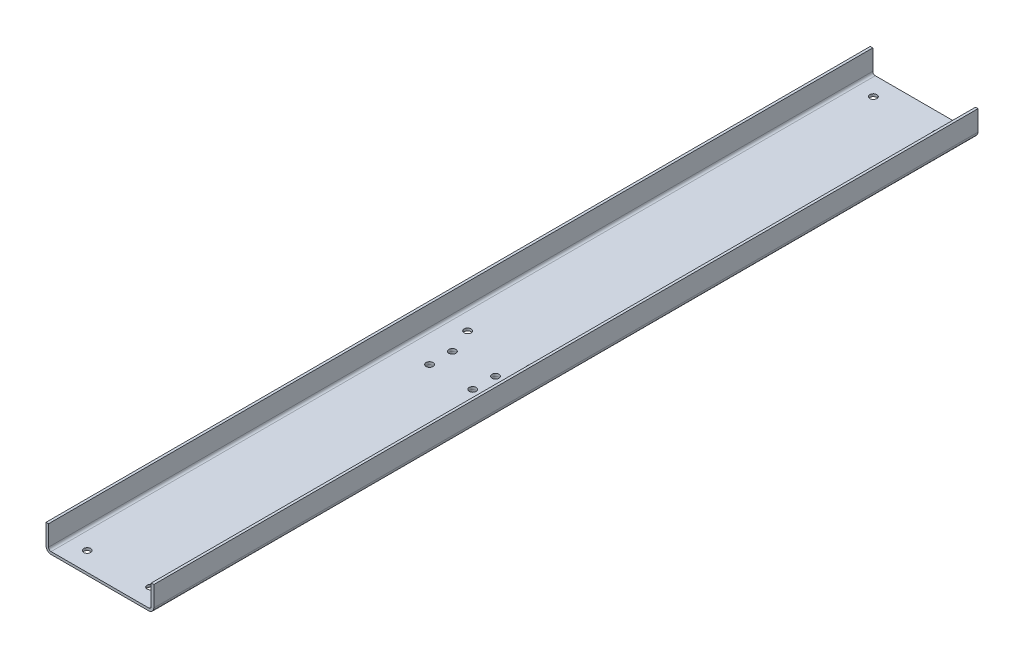
from build123d import *

# Parameters (mm, degrees)
BOSS_EXTRUDE1_DEPTH           = 650
FILLET1_R                     = 2
FILLET2_R                     = 4
SKETCH2_W                     = 46
SKETCH2_H                     = 30
BOSS_EXTRUDE2_DEPTH           = 6
CHAMFER1_SIZE                 = 3
SKETCH3_W                     = 2.75
SKETCH3_H                     = 8
M5_CLEARANCE_HOLE1_AT_2_COUNT = 2
M5_CLEARANCE_HOLE1_AT_2_PITCH = 620
M5_CLEARANCE_HOLE1_AT_3_COUNT = 2
M5_CLEARANCE_HOLE1_AT_3_PITCH = 50
M5_CLEARANCE_HOLE1_AT_4_COUNT = 2
M5_CLEARANCE_HOLE1_AT_4_PITCH = 323.882694814
M5_CLEARANCE_HOLE1_AT_5_COUNT = 2
M5_CLEARANCE_HOLE1_AT_5_PITCH = 320
M5_CLEARANCE_HOLE1_AT_6_COUNT = 2
M5_CLEARANCE_HOLE1_AT_6_PITCH = 622.012861603
SKETCH5_W                     = 2.75
SKETCH5_H                     = 8
M5_CLEARANCE_HOLE2_AT_2_COUNT = 2
M5_CLEARANCE_HOLE2_AT_2_PITCH = 34
M5_CLEARANCE_HOLE2_AT_3_COUNT = 2
M5_CLEARANCE_HOLE2_AT_3_PITCH = 38.470768123
M5_CLEARANCE_HOLE2_AT_4_COUNT = 2
M5_CLEARANCE_HOLE2_AT_4_PITCH = 18


with BuildPart() as part:
    # Sketch1 → Boss-Extrude1 (new body)
    with BuildSketch(Plane.XY):
        Polygon((40.5, 20), (42.5, 20), (42.5, 0), (-42.5, 0), (-42.5, 20), (-40.5, 20), (-40.5, 2), (40.5, 2), align=None)
    extrude(amount=BOSS_EXTRUDE1_DEPTH)

    # Fillet1
    fillet1_edges = [part.edges().sort_by_distance(p)[0] for p in [
        (-40.5, 2, 325),
        (40.5, 2, 325),
    ]]
    fillet(fillet1_edges, radius=FILLET1_R)

    # Fillet2
    fillet2_edges = [part.edges().sort_by_distance(p)[0] for p in [
        (42.5, 0, 325),
        (-42.5, 0, 325),
    ]]
    fillet(fillet2_edges, radius=FILLET2_R)

    # Sketch3 → M5 Clearance Hole1 (revolve, cut)
    with BuildSketch(Plane(origin=(-25, 2, 15), x_dir=(0, 0, 1), z_dir=(1, 0, 0))):
        with Locations((1.375, 4)):
            Rectangle(SKETCH3_W, SKETCH3_H)
    m5_clearance_hole1 = revolve(axis=Axis((-25, 8.35, 15), (0, -1, 0)), mode=Mode.SUBTRACT)

    # M5 Clearance Hole1 at 2: M5 Clearance Hole1 ×2
    with Locations(*[(0, 0, i * M5_CLEARANCE_HOLE1_AT_2_PITCH) for i in range(1, M5_CLEARANCE_HOLE1_AT_2_COUNT)]):
        add(m5_clearance_hole1, mode=Mode.SUBTRACT)

    # M5 Clearance Hole1 at 3: M5 Clearance Hole1 ×2
    with Locations(*[(i * M5_CLEARANCE_HOLE1_AT_3_PITCH, 0, 0) for i in range(1, M5_CLEARANCE_HOLE1_AT_3_COUNT)]):
        add(m5_clearance_hole1, mode=Mode.SUBTRACT)

    # M5 Clearance Hole1 at 4: M5 Clearance Hole1 ×2
    with Locations(*[Vector(0.15437688, 0, 0.988012034) * (i * M5_CLEARANCE_HOLE1_AT_4_PITCH) for i in range(1, M5_CLEARANCE_HOLE1_AT_4_COUNT)]):
        add(m5_clearance_hole1, mode=Mode.SUBTRACT)

    # M5 Clearance Hole1 at 5: M5 Clearance Hole1 ×2
    with Locations(*[(0, 0, i * M5_CLEARANCE_HOLE1_AT_5_PITCH) for i in range(1, M5_CLEARANCE_HOLE1_AT_5_COUNT)]):
        add(m5_clearance_hole1, mode=Mode.SUBTRACT)

    # M5 Clearance Hole1 at 6: M5 Clearance Hole1 ×2
    with Locations(*[Vector(0.08038419, 0, 0.996763955) * (i * M5_CLEARANCE_HOLE1_AT_6_PITCH) for i in range(1, M5_CLEARANCE_HOLE1_AT_6_COUNT)]):
        add(m5_clearance_hole1, mode=Mode.SUBTRACT)


with BuildPart() as body_2:
    # Sketch2 → Boss-Extrude2 (new body)
    with BuildSketch(Plane.XZ):
        with Locations((0, 364)):
            Rectangle(SKETCH2_W, SKETCH2_H)
    extrude(amount=BOSS_EXTRUDE2_DEPTH)

    # Chamfer1
    chamfer1_edges = [body_2.edges().sort_by_distance(p)[0] for p in [
        (23, -3, 349),
        (-23, -3, 349),
        (-23, -3, 379),
        (23, -3, 379),
    ]]
    chamfer(chamfer1_edges, length=CHAMFER1_SIZE)


with BuildPart() as m5_clearance_hole2_tool:
    # Sketch5 → M5 Clearance Hole2 (revolve)
    with BuildSketch(Plane(origin=(17, 2, 355), x_dir=(0, 0, 1), z_dir=(1, 0, 0))):
        with Locations((1.375, 4)):
            Rectangle(SKETCH5_W, SKETCH5_H)
    m5_clearance_hole2 = revolve(axis=Axis((17, 8.35, 355), (0, -1, 0)))


with BuildPart() as part_1:
    add(part.part)

    # M5 Clearance Hole2: cut by m5_clearance_hole2_tool
    add(m5_clearance_hole2_tool.part, mode=Mode.SUBTRACT)


with BuildPart() as body_2_1:
    add(body_2.part)

    # M5 Clearance Hole2: cut by m5_clearance_hole2_tool
    add(m5_clearance_hole2_tool.part, mode=Mode.SUBTRACT)


with BuildPart() as m5_clearance_hole2_at_2_tool:
    # M5 Clearance Hole2 at 2: M5 Clearance Hole2 ×2
    with Locations(*[(-i * M5_CLEARANCE_HOLE2_AT_2_PITCH, 0, 0) for i in range(1, M5_CLEARANCE_HOLE2_AT_2_COUNT)]):
        add(m5_clearance_hole2)


with BuildPart() as part_2:
    add(part_1.part)

    # M5 Clearance Hole2 at 2: cut by m5_clearance_hole2_at_2_tool
    add(m5_clearance_hole2_at_2_tool.part, mode=Mode.SUBTRACT)


with BuildPart() as body_2_2:
    add(body_2_1.part)

    # M5 Clearance Hole2 at 2: cut by m5_clearance_hole2_at_2_tool
    add(m5_clearance_hole2_at_2_tool.part, mode=Mode.SUBTRACT)


with BuildPart() as m5_clearance_hole2_at_3_tool:
    # M5 Clearance Hole2 at 3: M5 Clearance Hole2 ×2
    with Locations(*[Vector(-0.883787916, 0, 0.46788772) * (i * M5_CLEARANCE_HOLE2_AT_3_PITCH) for i in range(1, M5_CLEARANCE_HOLE2_AT_3_COUNT)]):
        add(m5_clearance_hole2)


with BuildPart() as part_3:
    add(part_2.part)

    # M5 Clearance Hole2 at 3: cut by m5_clearance_hole2_at_3_tool
    add(m5_clearance_hole2_at_3_tool.part, mode=Mode.SUBTRACT)


with BuildPart() as body_2_3:
    add(body_2_2.part)

    # M5 Clearance Hole2 at 3: cut by m5_clearance_hole2_at_3_tool
    add(m5_clearance_hole2_at_3_tool.part, mode=Mode.SUBTRACT)


with BuildPart() as m5_clearance_hole2_at_4_tool:
    # M5 Clearance Hole2 at 4: M5 Clearance Hole2 ×2
    with Locations(*[(0, 0, i * M5_CLEARANCE_HOLE2_AT_4_PITCH) for i in range(1, M5_CLEARANCE_HOLE2_AT_4_COUNT)]):
        add(m5_clearance_hole2)


with BuildPart() as part_4:
    add(part_3.part)

    # M5 Clearance Hole2 at 4: cut by m5_clearance_hole2_at_4_tool
    add(m5_clearance_hole2_at_4_tool.part, mode=Mode.SUBTRACT)


with BuildPart() as body_2_4:
    add(body_2_3.part)

    # M5 Clearance Hole2 at 4: cut by m5_clearance_hole2_at_4_tool
    add(m5_clearance_hole2_at_4_tool.part, mode=Mode.SUBTRACT)


solid = Compound([part_4.part, body_2_4.part])
